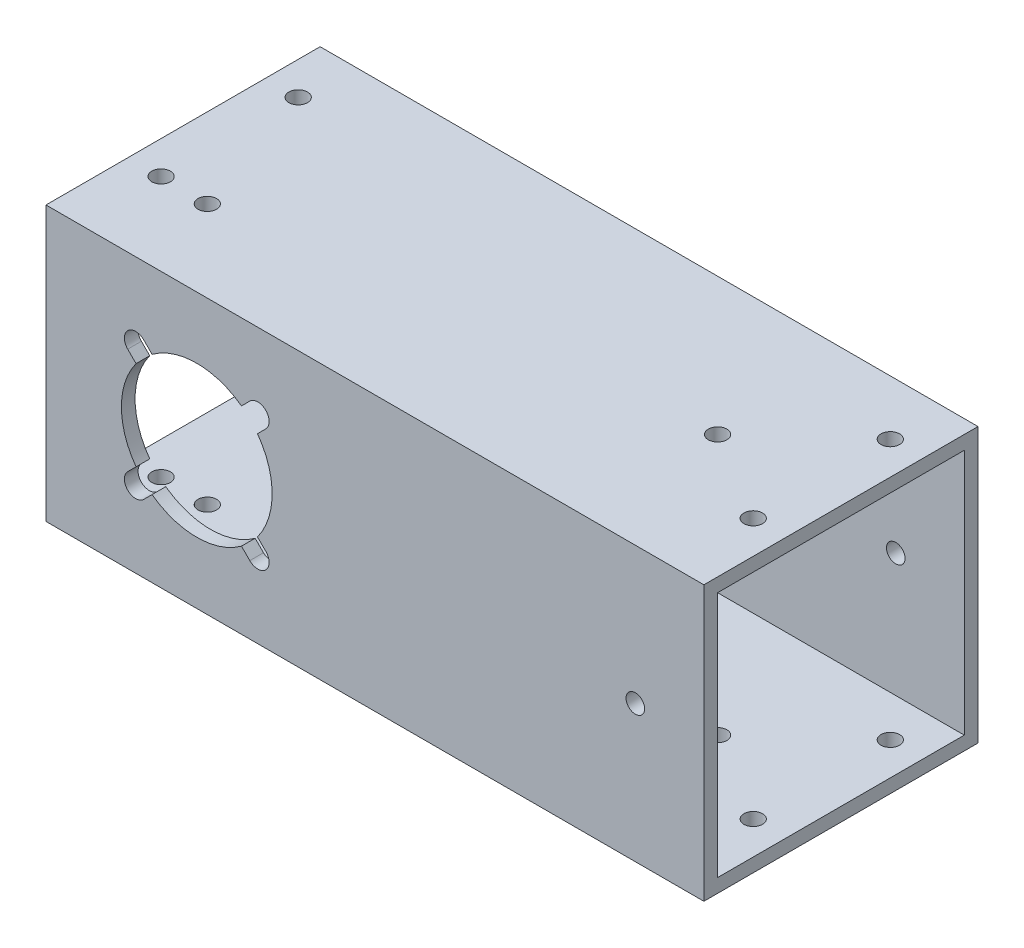
from build123d import *

# Parameters (mm, degrees)
SKETCH1_W             = 63.5
SKETCH1_H             = 63.5
BOSS_EXTRUDE1_DEPTH   = 704.85
SKETCH2_W             = 57.15
SKETCH2_H             = 57.15
CUT_EXTRUDE1_DEPTH    = 705.85
CUT_EXTRUDE2_REACH    = 65.5
SKETCH3_R             = 17.4625
SKETCH8_R             = 2.15265
CUT_EXTRUDE6_DEPTH    = 64.5
SKETCH10_R            = 2.15265
CUT_EXTRUDE7_DEPTH    = 64.5
CUT_EXTRUDE9_REACH    = 65.5
SKETCH13_R            = 16
SKETCH14_R            = 2.625
SKETCH14_R_2          = 16
CUT_EXTRUDE10_DEPTH   = 3.175
CUT_EXTRUDE11_START   = -3.175
CUT_EXTRUDE11_DEPTH   = 3.175
CUT_EXTRUDE13_REACH   = 65.5
SKETCH17_W            = 19.05
SKETCH17_H            = 25.4
SKETCH18_W            = 63.5
SKETCH18_H            = 63.5
CUT_EXTRUDE14_DEPTH   = 552.45
F_8_CLEARANCE_HOLE1_D = 4.3053
SKETCH21_R            = 2.15265
CUT_EXTRUDE15_DEPTH   = 6.35
SKETCH23_R            = 2.15265
CUT_EXTRUDE16_DEPTH   = 13.97


with BuildPart() as part:
    # Sketch1 → Boss-Extrude1 (new body)
    with BuildSketch(Plane(origin=(0, 0, 0), x_dir=(0, 0, -1), z_dir=(1, 0, 0))):
        Rectangle(SKETCH1_W, SKETCH1_H)
    extrude(amount=BOSS_EXTRUDE1_DEPTH)

    # Sketch2 → Cut-Extrude1 (cut, through all)
    with BuildSketch(Plane(origin=(704.85, 0, 0), x_dir=(0, 0, -1), z_dir=(1, 0, 0))):
        Rectangle(SKETCH2_W, SKETCH2_H)
    extrude(amount=-CUT_EXTRUDE1_DEPTH, mode=Mode.SUBTRACT)

    # Sketch3 → Cut-Extrude2 (cut, up to next)
    with BuildSketch(Plane.XY.offset(31.75), mode=Mode.PRIVATE) as cut_extrude2_sk1:
        with Locations((352.425, 0)):
            Circle(SKETCH3_R)
    cut_extrude2_tool1 = extrude(cut_extrude2_sk1.sketch, amount=-CUT_EXTRUDE2_REACH, mode=Mode.PRIVATE) & part.part
    add(cut_extrude2_tool1.solids().sort_by_distance((352.425, 0, 31.75))[0], mode=Mode.SUBTRACT)
    # Sketch3 → Cut-Extrude2 (cut, up to next)
    with BuildSketch(Plane.XY.offset(31.75), mode=Mode.PRIVATE) as cut_extrude2_sk2:
        with Locations((34.925, 0)):
            Circle(SKETCH3_R)
    cut_extrude2_tool2 = extrude(cut_extrude2_sk2.sketch, amount=-CUT_EXTRUDE2_REACH, mode=Mode.PRIVATE) & part.part
    add(cut_extrude2_tool2.solids().sort_by_distance((34.925, 0, 31.75))[0], mode=Mode.SUBTRACT)
    # Sketch3 → Cut-Extrude2 (cut, up to next)
    with BuildSketch(Plane.XY.offset(31.75), mode=Mode.PRIVATE) as cut_extrude2_sk3:
        with Locations((669.925, 0)):
            Circle(SKETCH3_R)
    cut_extrude2_tool3 = extrude(cut_extrude2_sk3.sketch, amount=-CUT_EXTRUDE2_REACH, mode=Mode.PRIVATE) & part.part
    add(cut_extrude2_tool3.solids().sort_by_distance((669.925, 0, 31.75))[0], mode=Mode.SUBTRACT)

    # Sketch8 → Cut-Extrude6 (cut, through all)
    with BuildSketch(Plane(origin=(0, 31.75, 0), x_dir=(1, 0, 0), z_dir=(0, 1, 0))):
        with Locations((466.725, 0)):
            Circle(SKETCH8_R)
        with Locations((123.825, 0)):
            Circle(SKETCH8_R)
        with Locations((581.025, 0)):
            Circle(SKETCH8_R)
        with Locations((238.125, 0)):
            Circle(SKETCH8_R)
    extrude(amount=-CUT_EXTRUDE6_DEPTH, mode=Mode.SUBTRACT)

    # Sketch10 → Cut-Extrude7 (cut, through all)
    with BuildSketch(Plane.XY.offset(31.75)):
        with Locations((225.425, 0)):
            Circle(SKETCH10_R)
        with Locations((568.325, 0)):
            Circle(SKETCH10_R)
        with Locations((136.525, 0)):
            Circle(SKETCH10_R)
        with Locations((479.425, 0)):
            Circle(SKETCH10_R)
    extrude(amount=-CUT_EXTRUDE7_DEPTH, mode=Mode.SUBTRACT)

    # Sketch13 → Cut-Extrude9 (cut, up to next)
    with BuildSketch(Plane(origin=(0, 0, -31.75), x_dir=(-1, 0, 0), z_dir=(0, 0, -1)), mode=Mode.PRIVATE) as cut_extrude9_sk1:
        with Locations((-352.425, 0)):
            Circle(SKETCH13_R)
    cut_extrude9_tool1 = extrude(cut_extrude9_sk1.sketch, amount=-CUT_EXTRUDE9_REACH, mode=Mode.PRIVATE) & part.part
    add(cut_extrude9_tool1.solids().sort_by_distance((352.425, 0, -31.75))[0], mode=Mode.SUBTRACT)
    # Sketch13 → Cut-Extrude9 (cut, up to next)
    with BuildSketch(Plane(origin=(0, 0, -31.75), x_dir=(-1, 0, 0), z_dir=(0, 0, -1)), mode=Mode.PRIVATE) as cut_extrude9_sk2:
        with Locations((-34.925, 0)):
            Circle(SKETCH13_R)
    cut_extrude9_tool2 = extrude(cut_extrude9_sk2.sketch, amount=-CUT_EXTRUDE9_REACH, mode=Mode.PRIVATE) & part.part
    add(cut_extrude9_tool2.solids().sort_by_distance((34.925, 0, -31.75))[0], mode=Mode.SUBTRACT)
    # Sketch13 → Cut-Extrude9 (cut, up to next)
    with BuildSketch(Plane(origin=(0, 0, -31.75), x_dir=(-1, 0, 0), z_dir=(0, 0, -1)), mode=Mode.PRIVATE) as cut_extrude9_sk3:
        with Locations((-669.925, 0)):
            Circle(SKETCH13_R)
    cut_extrude9_tool3 = extrude(cut_extrude9_sk3.sketch, amount=-CUT_EXTRUDE9_REACH, mode=Mode.PRIVATE) & part.part
    add(cut_extrude9_tool3.solids().sort_by_distance((669.925, 0, -31.75))[0], mode=Mode.SUBTRACT)

    # Sketch14 → Cut-Extrude10 (cut)
    with BuildSketch(Plane(origin=(0, 0, -31.75), x_dir=(-1, 0, 0), z_dir=(0, 0, -1))):
        with Locations((-655.782864376, 14.142135624)):
            Circle(SKETCH14_R)
        with Locations((-338.282864376, 14.142135624)):
            Circle(SKETCH14_R)
        with Locations((-20.782864376, 14.142135624)):
            Circle(SKETCH14_R)
        with Locations((-352.425, 0)):
            Circle(SKETCH14_R_2)
        with Locations((-34.925, 0)):
            Circle(SKETCH14_R_2)
        with Locations((-669.925, 0)):
            Circle(SKETCH14_R_2)
        with Locations((-338.282864376, -14.142135624)):
            Circle(SKETCH14_R)
        with Locations((-366.567135624, -14.142135624)):
            Circle(SKETCH14_R)
        with Locations((-366.567135624, 14.142135624)):
            Circle(SKETCH14_R)
        with Locations((-20.782864376, -14.142135624)):
            Circle(SKETCH14_R)
        with Locations((-49.067135624, -14.142135624)):
            Circle(SKETCH14_R)
        with Locations((-49.067135624, 14.142135624)):
            Circle(SKETCH14_R)
        with Locations((-655.782864376, -14.142135624)):
            Circle(SKETCH14_R)
        with Locations((-684.067135624, -14.142135624)):
            Circle(SKETCH14_R)
        with Locations((-684.067135624, 14.142135624)):
            Circle(SKETCH14_R)
    extrude(amount=-CUT_EXTRUDE10_DEPTH, mode=Mode.SUBTRACT)

    # Sketch15 → Cut-Extrude11 (cut)
    with BuildSketch(Plane.XY.offset(31.75).offset(CUT_EXTRUDE11_START)):
        with BuildLine():
            Line((364.710980323, -15.998290924), (362.776389114, -14.063699715))
            ThreePointArc((362.776389114, -14.063699715), (352.425, -17.4625), (342.073610886, -14.063699715))
            Line((342.073610886, -14.063699715), (340.139019677, -15.998290924))
            ThreePointArc((340.139019677, -15.998290924), (336.426709076, -15.998290924), (336.426709076, -12.285980323))
            Line((336.426709076, -12.285980323), (338.361300285, -10.351389114))
            ThreePointArc((338.361300285, -10.351389114), (334.9625, 0), (338.361300285, 10.351389114))
            Line((338.361300285, 10.351389114), (336.426709076, 12.285980323))
            ThreePointArc((336.426709076, 12.285980323), (336.426709076, 15.998290924), (340.139019677, 15.998290924))
            Line((340.139019677, 15.998290924), (342.073610886, 14.063699715))
            ThreePointArc((342.073610886, 14.063699715), (352.425, 17.4625), (362.776389114, 14.063699715))
            Line((362.776389114, 14.063699715), (364.710980323, 15.998290924))
            ThreePointArc((364.710980323, 15.998290924), (368.423290924, 15.998290924), (368.423290924, 12.285980323))
            Line((368.423290924, 12.285980323), (366.488699715, 10.351389114))
            ThreePointArc((366.488699715, 10.351389114), (369.8875, 0), (366.488699715, -10.351389114))
            Line((366.488699715, -10.351389114), (368.423290924, -12.285980323))
            ThreePointArc((368.423290924, -12.285980323), (368.423290924, -15.998290924), (364.710980323, -15.998290924))
        make_face()
        with BuildLine():
            Line((50.923290924, 12.285980323), (48.988699715, 10.351389114))
            ThreePointArc((48.988699715, 10.351389114), (52.3875, 0), (48.988699715, -10.351389114))
            Line((48.988699715, -10.351389114), (50.923290924, -12.285980323))
            ThreePointArc((50.923290924, -12.285980323), (50.923290924, -15.998290924), (47.210980323, -15.998290924))
            Line((47.210980323, -15.998290924), (45.276389114, -14.063699715))
            ThreePointArc((45.276389114, -14.063699715), (34.925, -17.4625), (24.573610886, -14.063699715))
            Line((24.573610886, -14.063699715), (22.639019677, -15.998290924))
            ThreePointArc((22.639019677, -15.998290924), (18.926709076, -15.998290924), (18.926709076, -12.285980323))
            Line((18.926709076, -12.285980323), (20.861300285, -10.351389114))
            ThreePointArc((20.861300285, -10.351389114), (17.4625, 0), (20.861300285, 10.351389114))
            Line((20.861300285, 10.351389114), (18.926709076, 12.285980323))
            ThreePointArc((18.926709076, 12.285980323), (18.926709076, 15.998290924), (22.639019677, 15.998290924))
            Line((22.639019677, 15.998290924), (24.573610886, 14.063699715))
            ThreePointArc((24.573610886, 14.063699715), (34.925, 17.4625), (45.276389114, 14.063699715))
            Line((45.276389114, 14.063699715), (47.210980323, 15.998290924))
            ThreePointArc((47.210980323, 15.998290924), (50.923290924, 15.998290924), (50.923290924, 12.285980323))
        make_face()
        with BuildLine():
            Line((685.923290924, 12.285980323), (683.988699715, 10.351389114))
            ThreePointArc((683.988699715, 10.351389114), (687.3875, 0), (683.988699715, -10.351389114))
            Line((683.988699715, -10.351389114), (685.923290924, -12.285980323))
            ThreePointArc((685.923290924, -12.285980323), (685.923290924, -15.998290924), (682.210980323, -15.998290924))
            Line((682.210980323, -15.998290924), (680.276389114, -14.063699715))
            ThreePointArc((680.276389114, -14.063699715), (669.925, -17.4625), (659.573610886, -14.063699715))
            Line((659.573610886, -14.063699715), (657.639019677, -15.998290924))
            ThreePointArc((657.639019677, -15.998290924), (653.926709076, -15.998290924), (653.926709076, -12.285980323))
            Line((653.926709076, -12.285980323), (655.861300285, -10.351389114))
            ThreePointArc((655.861300285, -10.351389114), (652.4625, 0), (655.861300285, 10.351389114))
            Line((655.861300285, 10.351389114), (653.926709076, 12.285980323))
            ThreePointArc((653.926709076, 12.285980323), (653.926709076, 15.998290924), (657.639019677, 15.998290924))
            Line((657.639019677, 15.998290924), (659.573610886, 14.063699715))
            ThreePointArc((659.573610886, 14.063699715), (669.925, 17.4625), (680.276389114, 14.063699715))
            Line((680.276389114, 14.063699715), (682.210980323, 15.998290924))
            ThreePointArc((682.210980323, 15.998290924), (685.923290924, 15.998290924), (685.923290924, 12.285980323))
        make_face()
    extrude(amount=CUT_EXTRUDE11_DEPTH, mode=Mode.SUBTRACT)

    # Sketch17 → Cut-Extrude13 (cut, up to next)
    with BuildSketch(Plane.XZ.offset(31.75), mode=Mode.PRIVATE) as cut_extrude13_sk1:
        with Locations((352.425, -12.7)):
            Rectangle(SKETCH17_W, SKETCH17_H)
    cut_extrude13_tool1 = extrude(cut_extrude13_sk1.sketch, amount=-CUT_EXTRUDE13_REACH, mode=Mode.PRIVATE) & part.part
    add(cut_extrude13_tool1.solids().sort_by_distance((352.425, -31.75, -12.7))[0], mode=Mode.SUBTRACT)

    # Sketch18 → Cut-Extrude14 (cut)
    with BuildSketch(Plane(origin=(704.85, 0, 0), x_dir=(0, 0, -1), z_dir=(1, 0, 0))):
        Rectangle(SKETCH18_W, SKETCH18_H)
    extrude(amount=-CUT_EXTRUDE14_DEPTH, mode=Mode.SUBTRACT)

    # #8 Clearance Hole1 (through all)
    with Locations(Plane(origin=(0, 31.75, 0), x_dir=(1, 0, 0), z_dir=(0, 1, 0))):
        with Locations((7.62, 19.05), (7.62, -12.7), (144.78, -12.7), (144.78, 19.05)):
            Hole(F_8_CLEARANCE_HOLE1_D / 2)

    # Sketch21 → Cut-Extrude15 (cut)
    with BuildSketch(Plane(origin=(0, -31.75, 0), x_dir=(-1, 0, 0), z_dir=(0, -1, 0))):
        with Locations((-18.4785, -12.85875)):
            Circle(SKETCH21_R)
    extrude(amount=-CUT_EXTRUDE15_DEPTH, mode=Mode.SUBTRACT)

    # Sketch23 → Cut-Extrude16 (cut)
    with BuildSketch(Plane(origin=(0, 28.575, 0), x_dir=(-1, 0, 0), z_dir=(0, -1, 0))):
        with Locations((-18.4785, -12.85875)):
            Circle(SKETCH23_R)
    extrude(amount=-CUT_EXTRUDE16_DEPTH, mode=Mode.SUBTRACT)


solid = part.part
